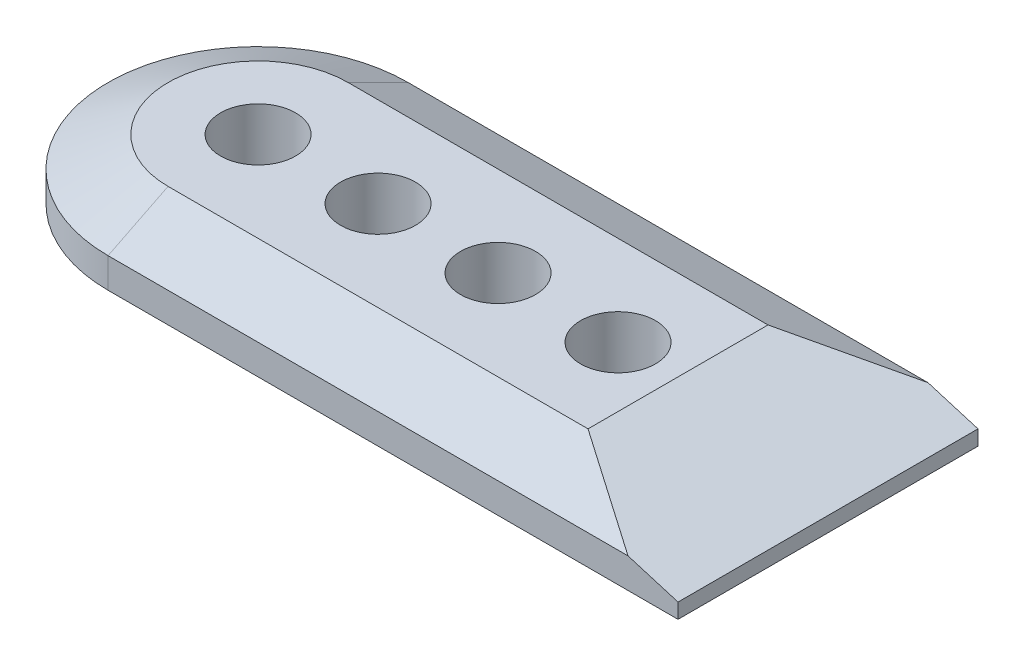
from build123d import *
from OCP.BRepFilletAPI import BRepFilletAPI_MakeChamfer

# Parameters (mm, degrees)
SKETCH1_R           = 3.125
BOSS_EXTRUDE1_DEPTH = 5
CHAMFER1_SIZE       = 2.5
CHAMFER1_SIZE2      = 5
CHAMFER2_SIZE       = 3.75
CHAMFER2_SIZE2      = 12.5


with BuildPart() as part:
    # Sketch1 → Boss-Extrude1 (new body)
    with BuildSketch(Plane(origin=(0, 0, 0), x_dir=(1, 0, 0), z_dir=(0, 1, 0))):
        with BuildLine():
            Line((0, -12.5), (0, 12.5))
            Line((0, 12.5), (-47.5, 12.5))
            ThreePointArc((-47.5, 12.5), (-60, 0), (-47.5, -12.5))
            Line((-47.5, -12.5), (0, -12.5))
        make_face()
        with Locations(Location((-47.5, 0, 0), (0, 0, 270))):
            Circle(SKETCH1_R, mode=Mode.SUBTRACT)
        with Locations(Location((-37.5, 0, 0), (0, 0, 270))):
            Circle(SKETCH1_R, mode=Mode.SUBTRACT)
        with Locations(Location((-27.5, 0, 0), (0, 0, 270))):
            Circle(SKETCH1_R, mode=Mode.SUBTRACT)
        with Locations(Location((-17.5, 0, 0), (0, 0, 270))):
            Circle(SKETCH1_R, mode=Mode.SUBTRACT)
    extrude(amount=BOSS_EXTRUDE1_DEPTH)

    # Chamfer1: one chamfer whose edges measure the first distance from different faces: ONE call of the kernel's chamfer builder (chamfer() names one face for all edges)
    chamfer1_edges_1 = [part.edges().sort_by_distance(p)[0] for p in [
        (-23.75, 5, -12.5),
    ]]
    chamfer1_side_1 = [part.faces().sort_by_distance(p)[0] for p in [
        (-23.75, 2.5, -12.5),
    ]]
    chamfer1_edges_2 = [part.edges().sort_by_distance(p)[0] for p in [
        (-60, 5, 0),
    ]]
    chamfer1_side_2 = [part.faces().sort_by_distance(p)[0] for p in [
        (-60, 2.5, 0),
    ]]
    chamfer1_edges_3 = [part.edges().sort_by_distance(p)[0] for p in [
        (-23.75, 5, 12.5),
    ]]
    chamfer1_side_3 = [part.faces().sort_by_distance(p)[0] for p in [
        (-23.75, 2.5, 12.5),
    ]]
    chamfer1 = BRepFilletAPI_MakeChamfer(part.part.solid().wrapped)
    for e in chamfer1_edges_1:
        chamfer1.Add(CHAMFER1_SIZE, CHAMFER1_SIZE2, e.wrapped, chamfer1_side_1[0].wrapped)  # the first distance lies on this face
    for e in chamfer1_edges_2:
        chamfer1.Add(CHAMFER1_SIZE, CHAMFER1_SIZE2, e.wrapped, chamfer1_side_2[0].wrapped)  # the first distance lies on this face
    for e in chamfer1_edges_3:
        chamfer1.Add(CHAMFER1_SIZE, CHAMFER1_SIZE2, e.wrapped, chamfer1_side_3[0].wrapped)  # the first distance lies on this face
    add(Compound.cast(chamfer1.Shape()), mode=Mode.REPLACE)

    # Chamfer2
    chamfer2_edges = [part.edges().sort_by_distance(p)[0] for p in [
        (0, 5, 0),
    ]]
    chamfer2_side = [part.faces().sort_by_distance(p)[0] for p in [
        (0, 2.314814815, 0),
    ]]
    chamfer(chamfer2_edges, length=CHAMFER2_SIZE, length2=CHAMFER2_SIZE2, reference=chamfer2_side[0])


solid = part.part
